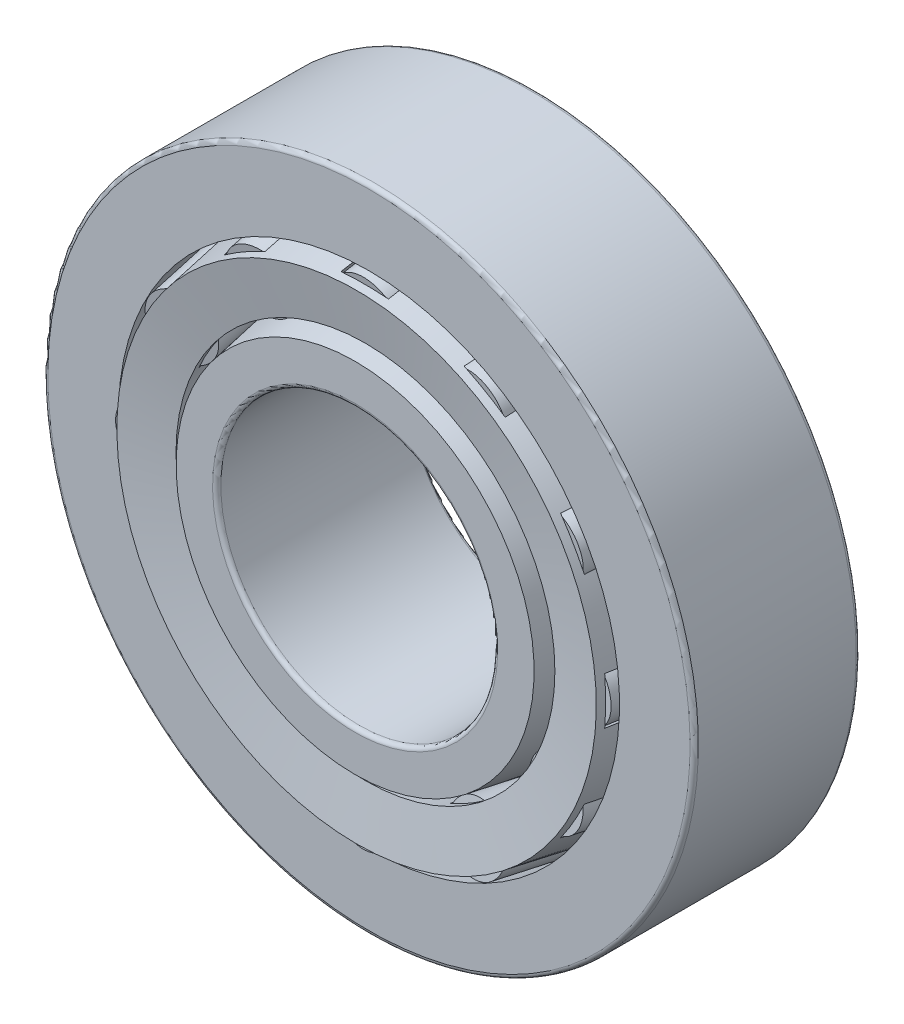
from build123d import *

# Parameters (mm, degrees)
CIRPATTERN1_COUNT = 12
CIRPATTERN2_COUNT = 12
CIRPATTERN2_ANGLE = 330
FILLET1_R         = 0.3
FILLET2_R         = 0.3


with BuildPart() as part:
    # Sketch1 → Revolve1 (revolve)
    with BuildSketch(Plane(origin=(0, 0, 0), x_dir=(0, 0, -1), z_dir=(1, 0, 0))):
        Polygon((-6, 23.5), (6, 23.5), (6, 20.215923769), (-6, 18.1), align=None)
    revolve(axis=Axis((0, 0, 7), (0, 0, -1)))

    # Fillet1
    fillet1_edges = [part.edges().sort_by_distance(p)[0] for p in [
        (0, -23.5, -6),
        (0, -23.5, 6),
    ]]
    fillet(fillet1_edges, radius=FILLET1_R)


with BuildPart() as body_2:
    # Sketch5 → Revolve4 (revolve)
    with BuildSketch(Plane(origin=(0, 0, 0), x_dir=(0, 0, -1), z_dir=(1, 0, 0))):
        Polygon((7, 15.4), (-7, 12.93142227), (-7, 10), (7, 10), align=None)
    revolve(axis=Axis((0, 0, 7), (0, 0, -1)))

    # Fillet2
    fillet2_edges = [body_2.edges().sort_by_distance(p)[0] for p in [
        (0, -10, 7),
        (0, -10, -7),
    ]]
    fillet(fillet2_edges, radius=FILLET2_R)


with BuildPart() as body_3:
    # Sketch2 → Revolve2 (revolve)
    with BuildSketch(Plane(origin=(0, 0, 0), x_dir=(0, 0, -1), z_dir=(1, 0, 0))):
        Polygon((-6.893284355, 17.318458523), (-6.252990486, 13.687171546), (6, 15.847704363), (8.143284355, 16.225623222), (7.502990486, 19.856910199), (6, 19.591892425), align=None)
    revolve(axis=Axis((0, 0, 7), (0, 0, -1)))

    # Sketch3 → Cut-Revolve1 (revolve, cut)
    with BuildSketch(Plane(origin=(0, 0, 0), x_dir=(0, 0, -1), z_dir=(1, 0, 0))):
        Polygon((-6, 15.603874625), (-6.426862579, 18.02473261), (5.573137421, 20.140656379), (6, 17.719798394), align=None)
    cut_revolve1 = revolve(axis=Axis((0, 15.502815034, 6.573137421), (0, 0.173648178, -0.984807753)), mode=Mode.SUBTRACT)

    # CirPattern1: Cut-Revolve1 ×12 about axis
    cirpattern1_axis = Axis((0, 0, 0), (0, 0, 1))
    for i in range(1, CIRPATTERN1_COUNT):
        add(cut_revolve1.rotate(cirpattern1_axis, i * 360 / CIRPATTERN1_COUNT), mode=Mode.SUBTRACT)


with BuildPart() as body_4:
    # Sketch4 → Revolve3 (revolve)
    with BuildSketch(Plane(origin=(0, 0, 0), x_dir=(0, 0, -1), z_dir=(1, 0, 0))):
        Polygon((-6.404809261, 17.899662026), (5.595190739, 20.015585794), (6, 17.719798394), (-6, 15.603874625), align=None)
    revolve(axis=Axis((0, 15.502815034, 6.573137421), (0, 0.173648178, -0.984807753)))


with BuildPart() as cirpattern2_1:
    # CirPattern2: pattern copy
    add(body_4.part.rotate(Axis((0, 0, -7), (0, 0, 1)), 1 * CIRPATTERN2_ANGLE / (CIRPATTERN2_COUNT - 1)))


with BuildPart() as cirpattern2_2:
    # CirPattern2: pattern copy
    add(body_4.part.rotate(Axis((0, 0, -7), (0, 0, 1)), 2 * CIRPATTERN2_ANGLE / (CIRPATTERN2_COUNT - 1)))


with BuildPart() as cirpattern2_3:
    # CirPattern2: pattern copy
    add(body_4.part.rotate(Axis((0, 0, -7), (0, 0, 1)), 3 * CIRPATTERN2_ANGLE / (CIRPATTERN2_COUNT - 1)))


with BuildPart() as cirpattern2_4:
    # CirPattern2: pattern copy
    add(body_4.part.rotate(Axis((0, 0, -7), (0, 0, 1)), 4 * CIRPATTERN2_ANGLE / (CIRPATTERN2_COUNT - 1)))


with BuildPart() as cirpattern2_5:
    # CirPattern2: pattern copy
    add(body_4.part.rotate(Axis((0, 0, -7), (0, 0, 1)), 5 * CIRPATTERN2_ANGLE / (CIRPATTERN2_COUNT - 1)))


with BuildPart() as cirpattern2_6:
    # CirPattern2: pattern copy
    add(body_4.part.rotate(Axis((0, 0, -7), (0, 0, 1)), 6 * CIRPATTERN2_ANGLE / (CIRPATTERN2_COUNT - 1)))


with BuildPart() as cirpattern2_7:
    # CirPattern2: pattern copy
    add(body_4.part.rotate(Axis((0, 0, -7), (0, 0, 1)), 7 * CIRPATTERN2_ANGLE / (CIRPATTERN2_COUNT - 1)))


with BuildPart() as cirpattern2_8:
    # CirPattern2: pattern copy
    add(body_4.part.rotate(Axis((0, 0, -7), (0, 0, 1)), 8 * CIRPATTERN2_ANGLE / (CIRPATTERN2_COUNT - 1)))


with BuildPart() as cirpattern2_9:
    # CirPattern2: pattern copy
    add(body_4.part.rotate(Axis((0, 0, -7), (0, 0, 1)), 9 * CIRPATTERN2_ANGLE / (CIRPATTERN2_COUNT - 1)))


with BuildPart() as cirpattern2_10:
    # CirPattern2: pattern copy
    add(body_4.part.rotate(Axis((0, 0, -7), (0, 0, 1)), 10 * CIRPATTERN2_ANGLE / (CIRPATTERN2_COUNT - 1)))


with BuildPart() as cirpattern2_11:
    # CirPattern2: pattern copy
    add(body_4.part.rotate(Axis((0, 0, -7), (0, 0, 1)), 11 * CIRPATTERN2_ANGLE / (CIRPATTERN2_COUNT - 1)))


solid = Compound([part.part, body_2.part, body_3.part, body_4.part, cirpattern2_1.part, cirpattern2_2.part, cirpattern2_3.part, cirpattern2_4.part, cirpattern2_5.part, cirpattern2_6.part, cirpattern2_7.part, cirpattern2_8.part, cirpattern2_9.part, cirpattern2_10.part, cirpattern2_11.part])
